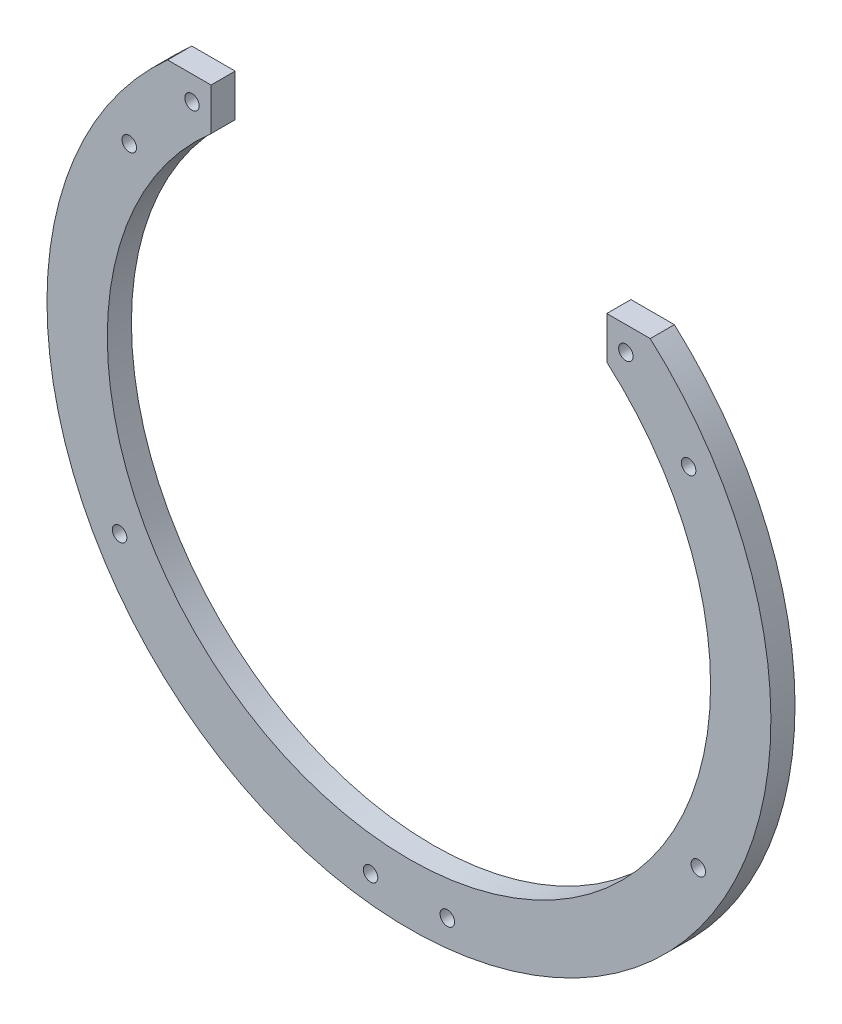
from build123d import *

# Parameters (mm, degrees)
RESSALTO_EXTRUS_O1_DEPTH = 5
ESBO_O2_R                = 1.5
CORTE_EXTRUS_O1_DEPTH    = 311.009274327
ESBO_O3_W                = 82
ESBO_O3_H                = 18.792940288
CORTE_EXTRUS_O2_DEPTH    = 10


with BuildPart() as part:
    # Esboço1 → Ressalto-extrusão1 (new body)
    with BuildSketch(Plane.XY):
        with BuildLine():
            Line((44.495405461, -168.430491325), (22.44625518, -168.430491325))
            ThreePointArc((22.44625518, -168.430491325), (-5.504594539, -286.832190763), (-33.455444258, -168.430491325))
            Line((-33.455444258, -168.430491325), (-55.504594539, -168.430491325))
            ThreePointArc((-55.504594539, -168.430491325), (-5.504594539, -299.332190763), (44.495405461, -168.430491325))
        make_face()
    extrude(amount=RESSALTO_EXTRUS_O1_DEPTH)

    # Esboço2 → Corte-extrusão1 (cut, through all)
    with BuildSketch(Plane.XY.offset(5)):
        with Locations((39.44625518, -173.430491325)):
            Circle(ESBO_O2_R)
        with Locations((52.44625518, -187.430491325)):
            Circle(ESBO_O2_R)
        with Locations((54.44625518, -258.430491325)):
            Circle(ESBO_O2_R)
        with Locations(Location((-13.455444258, -293.430491325, 0), (0, 0, 180))):
            Circle(ESBO_O2_R)
        with Locations((2.44625518, -293.430491325)):
            Circle(ESBO_O2_R)
        with Locations(Location((-65.455444258, -258.430491325, 0), (0, 0, 180))):
            Circle(ESBO_O2_R)
        with Locations(Location((-63.455444258, -187.430491325, 0), (0, 0, 180))):
            Circle(ESBO_O2_R)
        with Locations(Location((-50.455444258, -173.430491325, 0), (0, 0, 180))):
            Circle(ESBO_O2_R)
    extrude(amount=-CORTE_EXTRUS_O1_DEPTH, mode=Mode.SUBTRACT)

    # Esboço3 → Corte-extrusão2 (cut)
    with BuildSketch(Plane.XY.offset(5)):
        with Locations((-5.504594539, -170.544921833)):
            Rectangle(ESBO_O3_W, ESBO_O3_H)
    extrude(amount=-CORTE_EXTRUS_O2_DEPTH, mode=Mode.SUBTRACT)


solid = part.part
